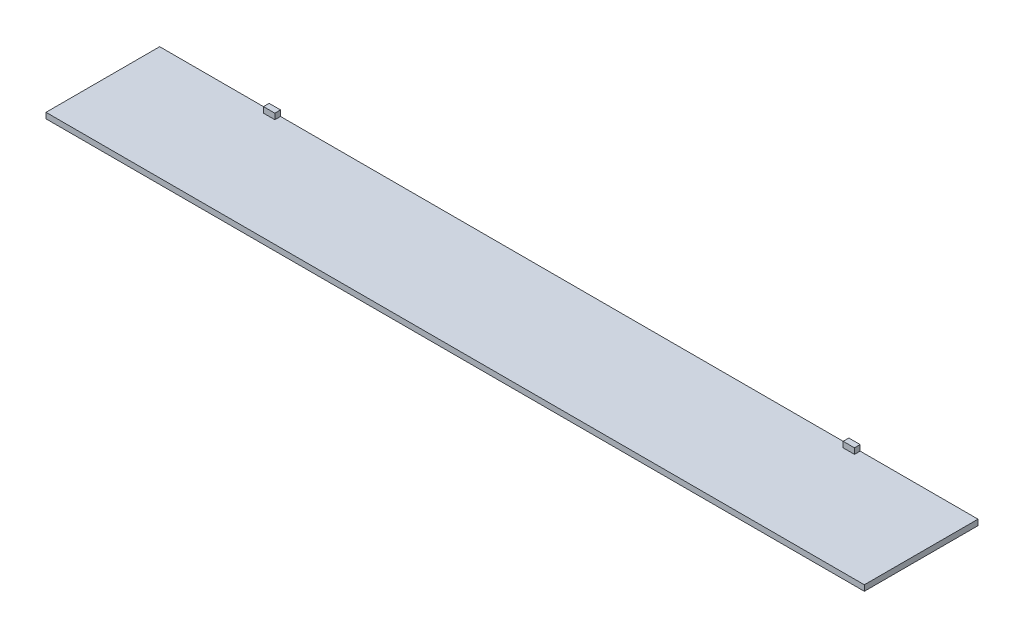
from build123d import *

# Parameters (mm, degrees)
SKETCH1_W           = 1440
SKETCH1_H           = 200
BOSS_EXTRUDE1_DEPTH = 10
SKETCH3_W           = 20
SKETCH3_H           = 10
BOSS_EXTRUDE3_DEPTH = 10


with BuildPart() as part:
    # Sketch1 → Boss-Extrude1 (new body)
    with BuildSketch(Plane(origin=(0, 0, 0), x_dir=(1, 0, 0), z_dir=(0, 1, 0))):
        Rectangle(SKETCH1_W, SKETCH1_H)
    extrude(amount=BOSS_EXTRUDE1_DEPTH)

    # Sketch3 → Boss-Extrude3 (add)
    with BuildSketch(Plane(origin=(0, 10, 0), x_dir=(1, 0, 0), z_dir=(0, 1, 0))):
        with Locations((-517.34, 95)):
            Rectangle(SKETCH3_W, SKETCH3_H)
        with Locations((502.66, 95)):
            Rectangle(SKETCH3_W, SKETCH3_H)
    extrude(amount=BOSS_EXTRUDE3_DEPTH)


solid = part.part
